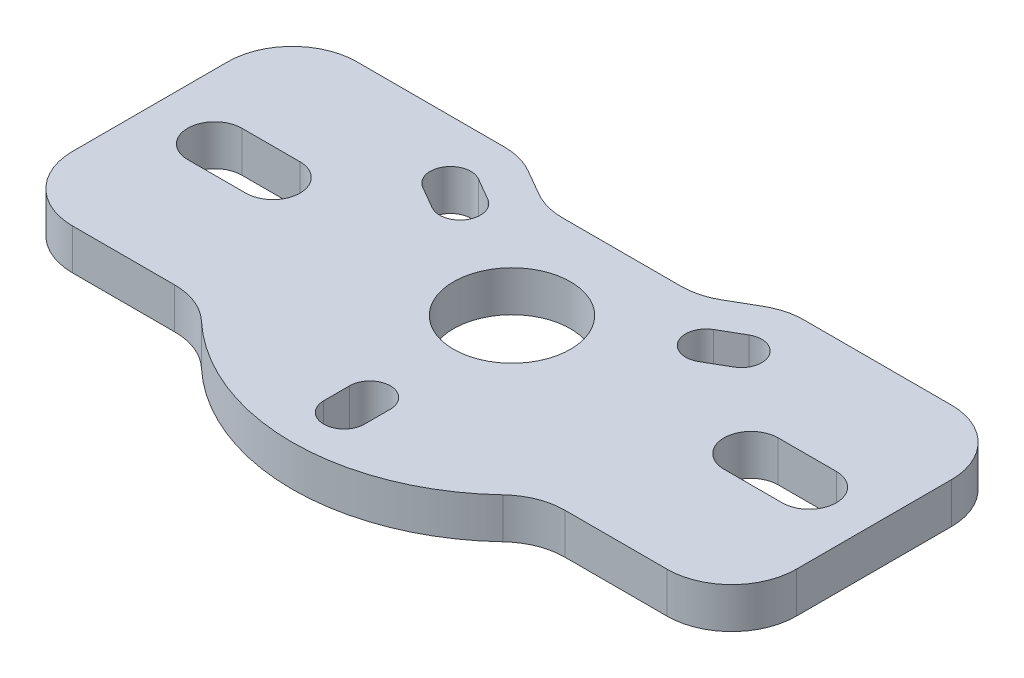
from build123d import *

# Parameters (mm, degrees)
SKETCH1_R           = 5.75
BOSS_EXTRUDE1_DEPTH = 4


with BuildPart() as part:
    # Sketch1 → Boss-Extrude1 (new body)
    with BuildSketch(Plane(origin=(0, 0, 0), x_dir=(1, 0, 0), z_dir=(0, 1, 0))):
        with BuildLine():
            Line((14.722227154, 13.97), (29.21, 13.97))
            ThreePointArc((29.21, 13.97), (33.700128061, 12.110128061), (35.56, 7.62))
            Line((35.56, 7.62), (35.56, -7.62))
            ThreePointArc((35.56, -7.62), (33.700128061, -12.110128061), (29.21, -13.97))
            Line((29.21, -13.97), (19.176579466, -13.97))
            ThreePointArc((19.176579466, -13.97), (16.831686562, -14.418815604), (14.818265951, -15.701818182))
            ThreePointArc((14.818265951, -15.701818182), (0, -21.59), (-14.818265951, -15.701818182))
            ThreePointArc((-14.818265951, -15.701818182), (-16.831686562, -14.418815604), (-19.176579466, -13.97))
            Line((-19.176579466, -13.97), (-29.21, -13.97))
            ThreePointArc((-29.21, -13.97), (-33.700128061, -12.110128061), (-35.56, -7.62))
            Line((-35.56, -7.62), (-35.56, 7.62))
            ThreePointArc((-35.56, 7.62), (-33.700128061, 12.110128061), (-29.21, 13.97))
            Line((-29.21, 13.97), (-14.722227154, 13.97))
            ThreePointArc((-14.722227154, 13.97), (-13.078726217, 13.753628997), (-11.547227154, 13.119261314))
            Line((-11.547227154, 13.119261314), (-8.995011096, 11.645738686))
            ThreePointArc((-8.995011096, 11.645738686), (-7.463512032, 11.011371003), (-5.820011096, 10.795))
            Line((-5.820011096, 10.795), (5.820011096, 10.795))
            ThreePointArc((5.820011096, 10.795), (7.463512032, 11.011371003), (8.995011096, 11.645738686))
            Line((8.995011096, 11.645738686), (11.547227154, 13.119261314))
            ThreePointArc((11.547227154, 13.119261314), (13.078726217, 13.753628997), (14.722227154, 13.97))
        make_face()
        Circle(SKETCH1_R, mode=Mode.SUBTRACT)
        with BuildLine():
            Line((-23.495, -2.667), (-29.21, -2.667))
            ThreePointArc((-29.21, -2.667), (-31.877, 0), (-29.21, 2.667))
            Line((-29.21, 2.667), (-23.495, 2.667))
            ThreePointArc((-23.495, 2.667), (-20.828, 0), (-23.495, -2.667))
        make_face(mode=Mode.SUBTRACT)
        with BuildLine():
            Line((23.495, 2.667), (29.21, 2.667))
            ThreePointArc((29.21, 2.667), (31.877, 0), (29.21, -2.667))
            Line((29.21, -2.667), (23.495, -2.667))
            ThreePointArc((23.495, -2.667), (20.828, 0), (23.495, 2.667))
        make_face(mode=Mode.SUBTRACT)
        with BuildLine():
            Line((-15.289419162, 6.517949192), (-13.089714637, 5.247949192))
            ThreePointArc((-13.089714637, 5.247949192), (-10.357663829, 5.98), (-11.089714637, 8.712050808))
            Line((-11.089714637, 8.712050808), (-13.289419162, 9.982050808))
            ThreePointArc((-13.289419162, 9.982050808), (-16.02146997, 9.25), (-15.289419162, 6.517949192))
        make_face(mode=Mode.SUBTRACT)
        with BuildLine():
            Line((13.289419162, 9.982050808), (11.089714637, 8.712050808))
            ThreePointArc((11.089714637, 8.712050808), (10.357663829, 5.98), (13.089714637, 5.247949192))
            Line((13.089714637, 5.247949192), (15.289419162, 6.517949192))
            ThreePointArc((15.289419162, 6.517949192), (16.02146997, 9.25), (13.289419162, 9.982050808))
        make_face(mode=Mode.SUBTRACT)
        with BuildLine():
            Line((2, -16.5), (2, -13.96))
            ThreePointArc((2, -13.96), (0, -11.96), (-2, -13.96))
            Line((-2, -13.96), (-2, -16.5))
            ThreePointArc((-2, -16.5), (0, -18.5), (2, -16.5))
        make_face(mode=Mode.SUBTRACT)
    extrude(amount=BOSS_EXTRUDE1_DEPTH)


solid = part.part
